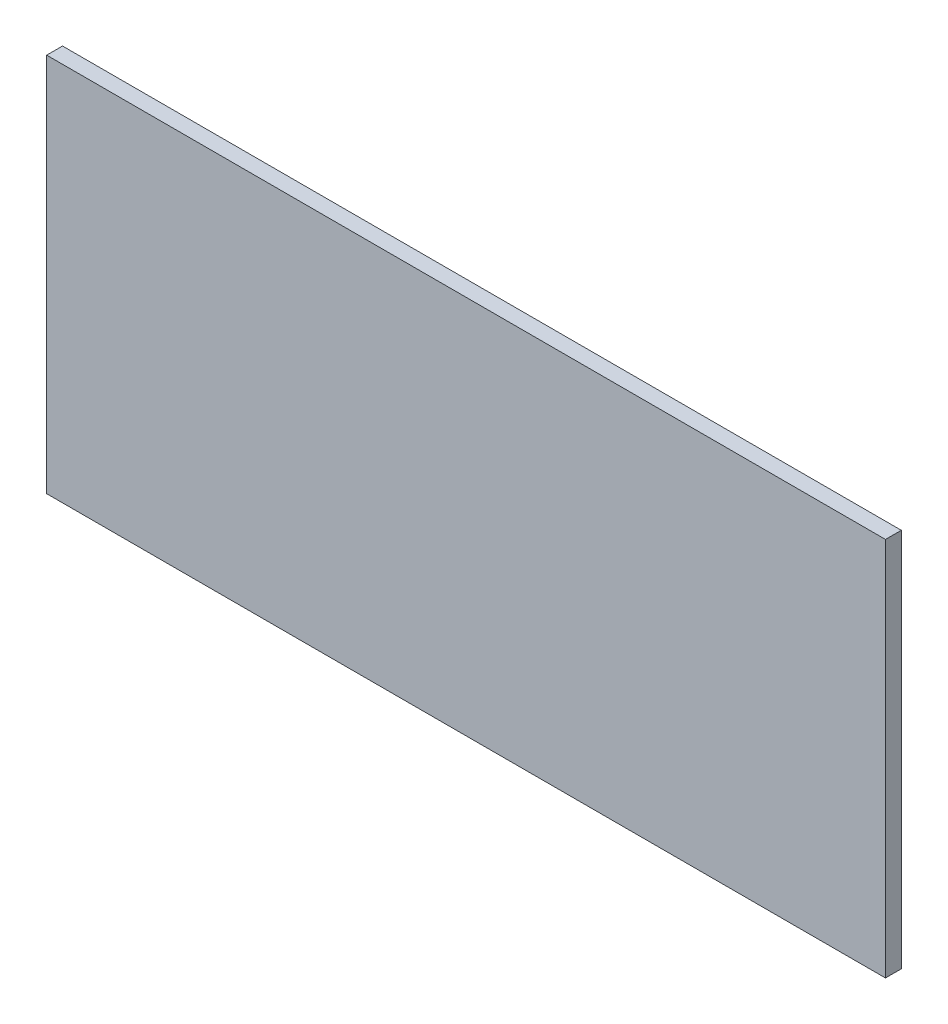
from build123d import *

# Parameters (mm, degrees)
SKETCH1_W           = 530
SKETCH1_H           = 240
BOSS_EXTRUDE1_DEPTH = 10


with BuildPart() as part:
    # Sketch1 → Boss-Extrude1 (new body)
    with BuildSketch(Plane.XY):
        Rectangle(SKETCH1_W, SKETCH1_H)
    extrude(amount=BOSS_EXTRUDE1_DEPTH)


solid = part.part
